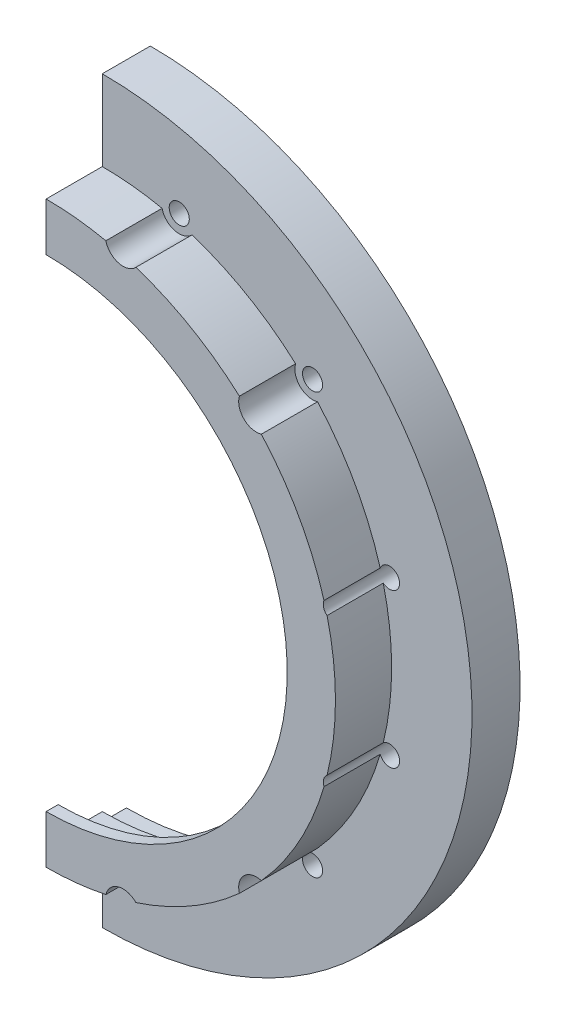
from build123d import *

# Parameters (mm, degrees)
SKETCH_3_R                   = 46
SKETCH_3_R_2                 = 34.6
EXTRUDE_2_DEPTH              = 3
SKETCH_5_R                   = 36
SKETCH_5_R_2                 = 33.5
EXTRUDE_3_DEPTH              = 5.49
SKETCH_2_R                   = 46
SKETCH_2_R_2                 = 41.6
EXTRUDE_1_DEPTH              = 2.98
SKETCH_6_R                   = 36
SKETCH_6_R_2                 = 30
EXTRUDE_4_DEPTH              = 1.5
EXTRUDE_5_DEPTH              = 3
EXTRUDE_5_DEPTH_BACK         = 2.98
SKETCH_12_W                  = 1.25
SKETCH_12_H                  = 5.98
HOLE_WIZARD_M3_1_AT_2_COUNT  = 2
HOLE_WIZARD_M3_1_AT_2_PITCH  = 64.085879878
HOLE_WIZARD_M3_1_AT_3_COUNT  = 2
HOLE_WIZARD_M3_1_AT_3_PITCH  = 71.478511138
HOLE_WIZARD_M3_1_AT_4_COUNT  = 2
HOLE_WIZARD_M3_1_AT_4_PITCH  = 73.999999995
HOLE_WIZARD_M3_1_AT_5_COUNT  = 2
HOLE_WIZARD_M3_1_AT_5_PITCH  = 19.15260934
HOLE_WIZARD_M3_1_AT_6_COUNT  = 2
HOLE_WIZARD_M3_1_AT_6_PITCH  = 36.999999998
HOLE_WIZARD_M3_1_AT_7_COUNT  = 2
HOLE_WIZARD_M3_1_AT_7_PITCH  = 52.325901805
HOLE_WIZARD_M3_1_AT_8_COUNT  = 2
HOLE_WIZARD_M3_1_AT_8_PITCH  = 71.47851114
HOLE_WIZARD_M3_1_AT_9_COUNT  = 2
HOLE_WIZARD_M3_1_AT_9_PITCH  = 64.085879872
HOLE_WIZARD_M3_1_AT_10_COUNT = 2
HOLE_WIZARD_M3_1_AT_10_PITCH = 52.325901805
HOLE_WIZARD_M3_1_AT_11_COUNT = 2
HOLE_WIZARD_M3_1_AT_11_PITCH = 36.999999994
HOLE_WIZARD_M3_1_AT_12_COUNT = 2
HOLE_WIZARD_M3_1_AT_12_PITCH = 19.152609334
CUT_EXTRUDE_1_REACH          = 8.99
SKETCH_13_R                  = 1.25
SKETCH_13_R_2                = 2.2
SKETCH_25_R                  = 3.25
CUT_EXTRUDE_9_DEPTH          = 10
EXTRUDE_7_DEPTH              = 4
EXTRUDE_7_DEPTH_BACK         = 2
FILLET_1_R                   = 5
SKETCH_27_W                  = 100
SKETCH_27_H                  = 92
CUT_EXTRUDE_10_DEPTH         = 10.99
CUT_EXTRUDE_10_DEPTH_BACK    = 40.48


with BuildPart() as part:
    # 草图3 → 凸台-拉伸2 (new body)
    with BuildSketch(Plane.XY):
        Circle(SKETCH_3_R)
        Circle(SKETCH_3_R_2, mode=Mode.SUBTRACT)
    extrude(amount=EXTRUDE_2_DEPTH)

    # 草图5 → 凸台-拉伸3 (add)
    with BuildSketch(Plane.XY.offset(3)):
        Circle(SKETCH_5_R)
        Circle(SKETCH_5_R_2, mode=Mode.SUBTRACT)
    extrude(amount=EXTRUDE_3_DEPTH)

    # 草图2 → 凸台-拉伸1 (add)
    with BuildSketch(Plane.XY):
        Circle(SKETCH_2_R)
        Circle(SKETCH_2_R_2, mode=Mode.SUBTRACT)
    extrude(amount=-EXTRUDE_1_DEPTH)

    # 草图6 → 凸台-拉伸4 (add)
    with BuildSketch(Plane.XY.offset(8.49)):
        Circle(SKETCH_6_R)
        Circle(SKETCH_6_R_2, mode=Mode.SUBTRACT)
    extrude(amount=EXTRUDE_4_DEPTH)

    # 草图8 → 凸台-拉伸5 (add, two sides)
    with BuildSketch(Plane.XY) as extrude_5_sk:
        with BuildLine():
            Line((-50, 20.008021569), (-45.01389718, 20.008021569))
            ThreePointArc((-45.01389718, 20.008021569), (-42.026432396, 20.80859551), (-39.839615313, 22.995761603))
            ThreePointArc((-39.839615313, 22.995761603), (-46, 0), (-39.839615313, -22.995761603))
            ThreePointArc((-39.839615313, -22.995761603), (-42.026432396, -20.80859551), (-45.01389718, -20.008021569))
            Line((-45.01389718, -20.008021569), (-50, -20.008021569))
            Line((-50, -20.008021569), (-50, 20.008021569))
        make_face()
    extrude(amount=EXTRUDE_5_DEPTH)
    extrude(extrude_5_sk.sketch, amount=-EXTRUDE_5_DEPTH_BACK)

    # 草图12 → M3 螺纹孔的螺纹孔钻头1 (revolve, cut)
    with BuildSketch(Plane(origin=(-35.73925557, -9.57630467, 3), x_dir=(0, -1, 0), z_dir=(1, 0, 0))):
        with Locations((0.625, 2.99)):
            Rectangle(SKETCH_12_W, SKETCH_12_H)
    hole_wizard_m3_1 = revolve(axis=Axis((-35.73925557, -9.57630467, 9.35), (0, 0, -1)), mode=Mode.SUBTRACT)

    # M3 螺纹孔的螺纹孔钻头1 at 2: M3 螺纹孔的螺纹孔钻头1 ×2
    with Locations(*[Vector(0.707106781, 0.707106781, 0) * (i * HOLE_WIZARD_M3_1_AT_2_PITCH) for i in range(1, HOLE_WIZARD_M3_1_AT_2_COUNT)]):
        add(hole_wizard_m3_1, mode=Mode.SUBTRACT)

    # M3 螺纹孔的螺纹孔钻头1 at 3: M3 螺纹孔的螺纹孔钻头1 ×2
    with Locations(*[Vector(0.866025404, 0.5, 0) * (i * HOLE_WIZARD_M3_1_AT_3_PITCH) for i in range(1, HOLE_WIZARD_M3_1_AT_3_COUNT)]):
        add(hole_wizard_m3_1, mode=Mode.SUBTRACT)

    # M3 螺纹孔的螺纹孔钻头1 at 4: M3 螺纹孔的螺纹孔钻头1 ×2
    with Locations(*[Vector(0.965925826, 0.258819045, 0) * (i * HOLE_WIZARD_M3_1_AT_4_PITCH) for i in range(1, HOLE_WIZARD_M3_1_AT_4_COUNT)]):
        add(hole_wizard_m3_1, mode=Mode.SUBTRACT)

    # M3 螺纹孔的螺纹孔钻头1 at 5: M3 螺纹孔的螺纹孔钻头1 ×2
    with Locations(*[(0, i * HOLE_WIZARD_M3_1_AT_5_PITCH, 0) for i in range(1, HOLE_WIZARD_M3_1_AT_5_COUNT)]):
        add(hole_wizard_m3_1, mode=Mode.SUBTRACT)

    # M3 螺纹孔的螺纹孔钻头1 at 6: M3 螺纹孔的螺纹孔钻头1 ×2
    with Locations(*[Vector(0.258819045, 0.965925826, 0) * (i * HOLE_WIZARD_M3_1_AT_6_PITCH) for i in range(1, HOLE_WIZARD_M3_1_AT_6_COUNT)]):
        add(hole_wizard_m3_1, mode=Mode.SUBTRACT)

    # M3 螺纹孔的螺纹孔钻头1 at 7: M3 螺纹孔的螺纹孔钻头1 ×2
    with Locations(*[Vector(0.5, 0.866025404, 0) * (i * HOLE_WIZARD_M3_1_AT_7_PITCH) for i in range(1, HOLE_WIZARD_M3_1_AT_7_COUNT)]):
        add(hole_wizard_m3_1, mode=Mode.SUBTRACT)

    # M3 螺纹孔的螺纹孔钻头1 at 8: M3 螺纹孔的螺纹孔钻头1 ×2
    with Locations(*[(i * HOLE_WIZARD_M3_1_AT_8_PITCH, 0, 0) for i in range(1, HOLE_WIZARD_M3_1_AT_8_COUNT)]):
        add(hole_wizard_m3_1, mode=Mode.SUBTRACT)

    # M3 螺纹孔的螺纹孔钻头1 at 9: M3 螺纹孔的螺纹孔钻头1 ×2
    with Locations(*[Vector(0.965925826, -0.258819045, 0) * (i * HOLE_WIZARD_M3_1_AT_9_PITCH) for i in range(1, HOLE_WIZARD_M3_1_AT_9_COUNT)]):
        add(hole_wizard_m3_1, mode=Mode.SUBTRACT)

    # M3 螺纹孔的螺纹孔钻头1 at 10: M3 螺纹孔的螺纹孔钻头1 ×2
    with Locations(*[Vector(0.866025404, -0.5, 0) * (i * HOLE_WIZARD_M3_1_AT_10_PITCH) for i in range(1, HOLE_WIZARD_M3_1_AT_10_COUNT)]):
        add(hole_wizard_m3_1, mode=Mode.SUBTRACT)

    # M3 螺纹孔的螺纹孔钻头1 at 11: M3 螺纹孔的螺纹孔钻头1 ×2
    with Locations(*[Vector(0.707106781, -0.707106781, 0) * (i * HOLE_WIZARD_M3_1_AT_11_PITCH) for i in range(1, HOLE_WIZARD_M3_1_AT_11_COUNT)]):
        add(hole_wizard_m3_1, mode=Mode.SUBTRACT)

    # M3 螺纹孔的螺纹孔钻头1 at 12: M3 螺纹孔的螺纹孔钻头1 ×2
    with Locations(*[Vector(0.5, -0.866025404, 0) * (i * HOLE_WIZARD_M3_1_AT_12_PITCH) for i in range(1, HOLE_WIZARD_M3_1_AT_12_COUNT)]):
        add(hole_wizard_m3_1, mode=Mode.SUBTRACT)

    # 草图13 → 切除-拉伸1 (cut, up to next)
    with BuildSketch(Plane.XY.offset(3), mode=Mode.PRIVATE) as cut_extrude_1_sk1:
        with Locations((-35.73925557, -9.57630467)):
            Circle(SKETCH_13_R)
    cut_extrude_1_tool1 = extrude(cut_extrude_1_sk1.sketch, amount=CUT_EXTRUDE_1_REACH, mode=Mode.PRIVATE) & part.part
    add(cut_extrude_1_tool1.solids().sort_by_distance((-35.739256, -9.576305, 3))[0], mode=Mode.SUBTRACT)
    # 草图13 → 切除-拉伸1 (cut, up to next)
    with BuildSketch(Plane.XY.offset(3), mode=Mode.PRIVATE) as cut_extrude_1_sk2:
        with Locations((-26.1629509, -26.1629509)):
            Circle(SKETCH_13_R_2)
    cut_extrude_1_tool2 = extrude(cut_extrude_1_sk2.sketch, amount=CUT_EXTRUDE_1_REACH, mode=Mode.PRIVATE) & part.part
    add(cut_extrude_1_tool2.solids().sort_by_distance((-26.162951, -26.162951, 3))[0], mode=Mode.SUBTRACT)
    # 草图13 → 切除-拉伸1 (cut, up to next)
    with BuildSketch(Plane.XY.offset(3), mode=Mode.PRIVATE) as cut_extrude_1_sk3:
        with Locations((-35.73925557, 9.57630467)):
            Circle(SKETCH_13_R)
    cut_extrude_1_tool3 = extrude(cut_extrude_1_sk3.sketch, amount=CUT_EXTRUDE_1_REACH, mode=Mode.PRIVATE) & part.part
    add(cut_extrude_1_tool3.solids().sort_by_distance((-35.739256, 9.576305, 3))[0], mode=Mode.SUBTRACT)
    # 草图13 → 切除-拉伸1 (cut, up to next)
    with BuildSketch(Plane.XY.offset(3), mode=Mode.PRIVATE) as cut_extrude_1_sk4:
        with Locations((-26.1629509, 26.1629509)):
            Circle(SKETCH_13_R_2)
    cut_extrude_1_tool4 = extrude(cut_extrude_1_sk4.sketch, amount=CUT_EXTRUDE_1_REACH, mode=Mode.PRIVATE) & part.part
    add(cut_extrude_1_tool4.solids().sort_by_distance((-26.162951, 26.162951, 3))[0], mode=Mode.SUBTRACT)
    # 草图13 → 切除-拉伸1 (cut, up to next)
    with BuildSketch(Plane.XY.offset(3), mode=Mode.PRIVATE) as cut_extrude_1_sk5:
        with Locations((-9.57630467, 35.73925557)):
            Circle(SKETCH_13_R_2)
    cut_extrude_1_tool5 = extrude(cut_extrude_1_sk5.sketch, amount=CUT_EXTRUDE_1_REACH, mode=Mode.PRIVATE) & part.part
    add(cut_extrude_1_tool5.solids().sort_by_distance((-9.576305, 35.739256, 3))[0], mode=Mode.SUBTRACT)
    # 草图13 → 切除-拉伸1 (cut, up to next)
    with BuildSketch(Plane.XY.offset(3), mode=Mode.PRIVATE) as cut_extrude_1_sk6:
        with Locations((26.1629509, 26.1629509)):
            Circle(SKETCH_13_R_2)
    cut_extrude_1_tool6 = extrude(cut_extrude_1_sk6.sketch, amount=CUT_EXTRUDE_1_REACH, mode=Mode.PRIVATE) & part.part
    add(cut_extrude_1_tool6.solids().sort_by_distance((26.162951, 26.162951, 3))[0], mode=Mode.SUBTRACT)
    # 草图13 → 切除-拉伸1 (cut, up to next)
    with BuildSketch(Plane.XY.offset(3), mode=Mode.PRIVATE) as cut_extrude_1_sk7:
        with Locations((35.73925557, 9.57630467)):
            Circle(SKETCH_13_R)
    cut_extrude_1_tool7 = extrude(cut_extrude_1_sk7.sketch, amount=CUT_EXTRUDE_1_REACH, mode=Mode.PRIVATE) & part.part
    add(cut_extrude_1_tool7.solids().sort_by_distance((35.739256, 9.576305, 3))[0], mode=Mode.SUBTRACT)
    # 草图13 → 切除-拉伸1 (cut, up to next)
    with BuildSketch(Plane.XY.offset(3), mode=Mode.PRIVATE) as cut_extrude_1_sk8:
        with Locations((35.73925557, -9.57630467)):
            Circle(SKETCH_13_R)
    cut_extrude_1_tool8 = extrude(cut_extrude_1_sk8.sketch, amount=CUT_EXTRUDE_1_REACH, mode=Mode.PRIVATE) & part.part
    add(cut_extrude_1_tool8.solids().sort_by_distance((35.739256, -9.576305, 3))[0], mode=Mode.SUBTRACT)
    # 草图13 → 切除-拉伸1 (cut, up to next)
    with BuildSketch(Plane.XY.offset(3), mode=Mode.PRIVATE) as cut_extrude_1_sk9:
        with Locations((9.57630467, -35.73925557)):
            Circle(SKETCH_13_R_2)
    cut_extrude_1_tool9 = extrude(cut_extrude_1_sk9.sketch, amount=CUT_EXTRUDE_1_REACH, mode=Mode.PRIVATE) & part.part
    add(cut_extrude_1_tool9.solids().sort_by_distance((9.576305, -35.739256, 3))[0], mode=Mode.SUBTRACT)
    # 草图13 → 切除-拉伸1 (cut, up to next)
    with BuildSketch(Plane.XY.offset(3), mode=Mode.PRIVATE) as cut_extrude_1_sk10:
        with Locations((-9.57630467, -35.73925557)):
            Circle(SKETCH_13_R_2)
    cut_extrude_1_tool10 = extrude(cut_extrude_1_sk10.sketch, amount=CUT_EXTRUDE_1_REACH, mode=Mode.PRIVATE) & part.part
    add(cut_extrude_1_tool10.solids().sort_by_distance((-9.576305, -35.739256, 3))[0], mode=Mode.SUBTRACT)
    # 草图13 → 切除-拉伸1 (cut, up to next)
    with BuildSketch(Plane.XY.offset(3), mode=Mode.PRIVATE) as cut_extrude_1_sk11:
        with Locations((9.57630467, 35.73925557)):
            Circle(SKETCH_13_R_2)
    cut_extrude_1_tool11 = extrude(cut_extrude_1_sk11.sketch, amount=CUT_EXTRUDE_1_REACH, mode=Mode.PRIVATE) & part.part
    add(cut_extrude_1_tool11.solids().sort_by_distance((9.576305, 35.739256, 3))[0], mode=Mode.SUBTRACT)
    # 草图13 → 切除-拉伸1 (cut, up to next)
    with BuildSketch(Plane.XY.offset(3), mode=Mode.PRIVATE) as cut_extrude_1_sk12:
        with Locations((26.1629509, -26.1629509)):
            Circle(SKETCH_13_R_2)
    cut_extrude_1_tool12 = extrude(cut_extrude_1_sk12.sketch, amount=CUT_EXTRUDE_1_REACH, mode=Mode.PRIVATE) & part.part
    add(cut_extrude_1_tool12.solids().sort_by_distance((26.162951, -26.162951, 3))[0], mode=Mode.SUBTRACT)

    # 草图25 → 切除-拉伸9 (cut)
    with BuildSketch(Plane.XY.offset(3)):
        with Locations((-9.57630467, 35.73925557)):
            Circle(SKETCH_25_R)
        with Locations((-26.1629509, 26.1629509)):
            Circle(SKETCH_25_R)
        with Locations((-35.73925557, 9.57630467)):
            Circle(SKETCH_25_R)
        with Locations((-35.73925557, -9.57630467)):
            Circle(SKETCH_25_R)
        with Locations((-26.1629509, -26.1629509)):
            Circle(SKETCH_25_R)
        with Locations((-9.57630467, -35.73925557)):
            Circle(SKETCH_25_R)
    extrude(amount=CUT_EXTRUDE_9_DEPTH, mode=Mode.SUBTRACT)

    # 草图26 → 凸台-拉伸7 (add, two sides)
    with BuildSketch(Plane.ZY.offset(50)) as extrude_7_sk:
        with BuildLine():
            ThreePointArc((-12.98, 26.5), (-39.48, 0), (-12.98, -26.5))
            ThreePointArc((-12.98, -26.5), (-9.999377331, -25.617338519), (-7.98, -23.254010785))
            ThreePointArc((-7.98, -23.254010785), (-5.960622669, -20.89068305), (-2.98, -20.008021569))
            Line((-2.98, -20.008021569), (3, -20.008021569))
            Line((3, -20.008021569), (3, 20.008021569))
            Line((3, 20.008021569), (-2.98, 20.008021569))
            ThreePointArc((-2.98, 20.008021569), (-5.960622669, 20.89068305), (-7.98, 23.254010785))
            ThreePointArc((-7.98, 23.254010785), (-9.999377331, 25.617338519), (-12.98, 26.5))
        make_face()
    extrude(amount=EXTRUDE_7_DEPTH)
    extrude(extrude_7_sk.sketch, amount=-EXTRUDE_7_DEPTH_BACK)

    # 圆角1
    fillet_1_edges = [part.edges().sort_by_distance(p)[0] for p in [
        (-54, 0, 3),
    ]]
    fillet(fillet_1_edges, radius=FILLET_1_R)

    # 草图27 → 切除-拉伸10 (cut, two sides)
    with BuildSketch(Plane.XY) as cut_extrude_10_sk:
        with Locations((-50, 0)):
            Rectangle(SKETCH_27_W, SKETCH_27_H)
    extrude(amount=CUT_EXTRUDE_10_DEPTH, mode=Mode.SUBTRACT)
    extrude(cut_extrude_10_sk.sketch, amount=-CUT_EXTRUDE_10_DEPTH_BACK, mode=Mode.SUBTRACT)


solid = part.part
